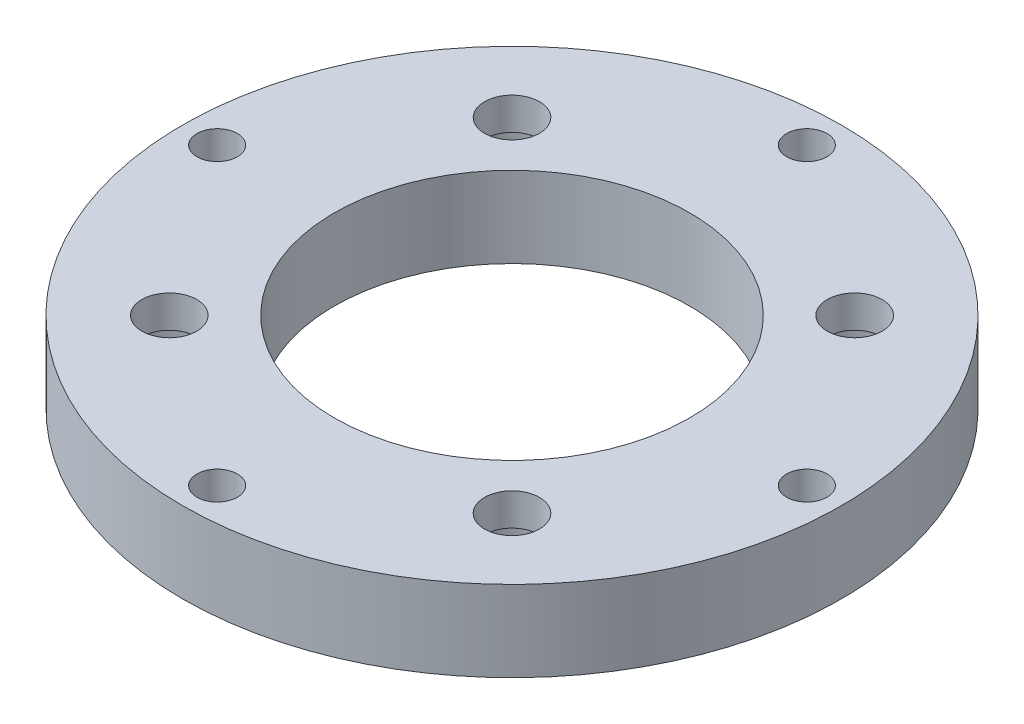
from build123d import *

# Parameters (mm, degrees)
SKETCH_1_R                  = 20.4
SKETCH_1_R_2                = 11
EXTRUDE_1_DEPTH             = 5
M3X0_51_D                   = 2.5
HOLE_WIZARD_M31_D           = 3.4
HOLE_WIZARD_M31_CBORE_D     = 6.5
HOLE_WIZARD_M31_CBORE_DEPTH = 3


with BuildPart() as part:
    # Эскиз1 → Бобышка-Вытянуть1 (new body)
    with BuildSketch(Plane(origin=(0, 0, 0), x_dir=(1, 0, 0), z_dir=(0, 1, 0))):
        Circle(SKETCH_1_R)
        Circle(SKETCH_1_R_2, mode=Mode.SUBTRACT)
    extrude(amount=EXTRUDE_1_DEPTH)

    # Отверстие обработанное метчиком M3x0.51 (through all)
    with Locations(Plane(origin=(0, 5, 0), x_dir=(1, 0, 0), z_dir=(0, 1, 0))):
        with Locations((-18.25, 0), (0, 18.25), (18.25, 0), (0, -18.25)):
            Hole(M3X0_51_D / 2)

    # Цековка для винта с внутренним шестигранником M31 (through all)
    with Locations(Plane(origin=(0, 0, 0), x_dir=(-1, 0, 0), z_dir=(0, -1, 0))):
        with Locations((10.606601718, -10.606601718), (-10.606601718, -10.606601718), (-10.606601718, 10.606601718), (10.606601718, 10.606601718)):
            CounterBoreHole(HOLE_WIZARD_M31_D / 2, HOLE_WIZARD_M31_CBORE_D / 2, HOLE_WIZARD_M31_CBORE_DEPTH)


solid = part.part
